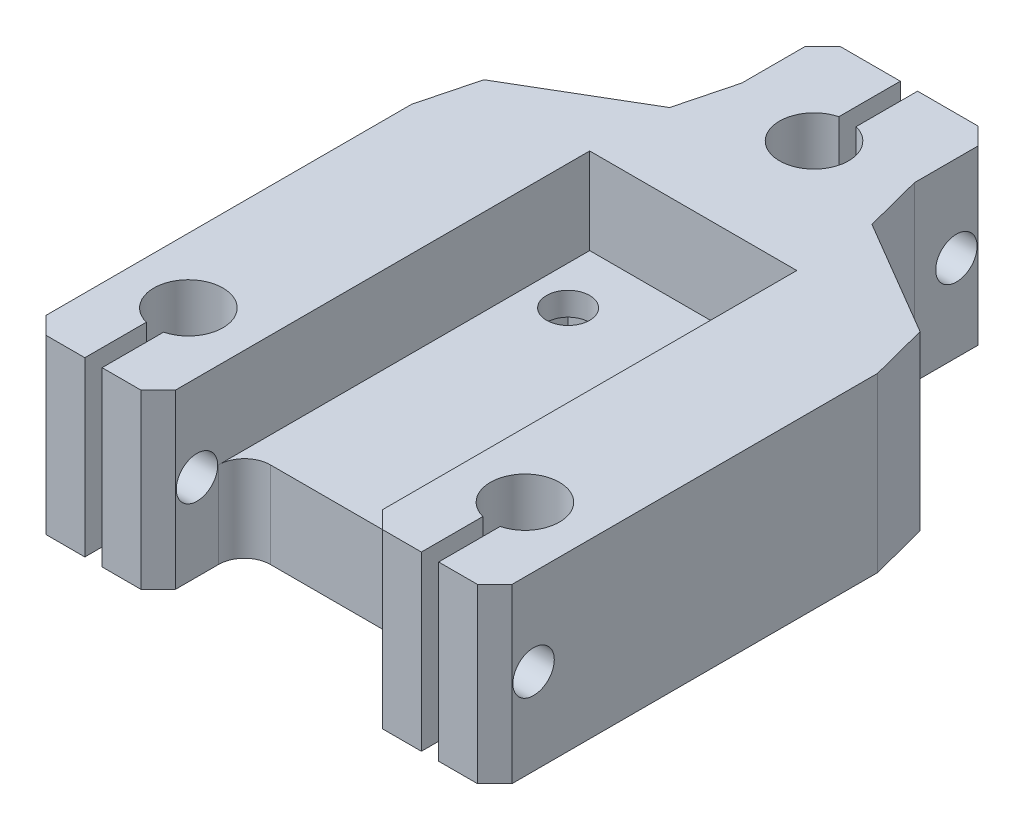
from build123d import *

# Parameters (mm, degrees)
SKETCH1_W             = 24
SKETCH1_H             = 40
SKETCH1_R             = 2.5
BOSS_EXTRUDE1_DEPTH   = 10
SKETCH2_R             = 4
BOSS_EXTRUDE2_DEPTH   = 20
SKETCH4_W             = 2
SKETCH4_H             = 15
CUT_EXTRUDE1_DEPTH    = 20
SKETCH5_R             = 2.4
CUT_EXTRUDE2_DEPTH    = 56
CHAMFER2_SIZE         = 2
CHAMFER3_SIZE2        = 2
CHAMFER3_SIZE         = 5.63516655
CHAMFER3_EDGE_2_SIZE2 = 5.63516655
CHAMFER3_EDGE_2_SIZE  = 2
CHAMFER3_EDGE_3_SIZE2 = 2
CHAMFER3_EDGE_3_SIZE  = 5.63516655
CHAMFER3_EDGE_4_SIZE2 = 5.63516655
CHAMFER3_EDGE_4_SIZE  = 2
FILLET2_R             = 3
SKETCH6_W             = 28
SKETCH6_H             = 13
CUT_EXTRUDE3_DEPTH    = 7.3


with BuildPart() as part:
    # Sketch1 → Boss-Extrude1 (new body)
    with BuildSketch(Plane(origin=(0, 0, 0), x_dir=(1, 0, 0), z_dir=(0, 1, 0))):
        Rectangle(SKETCH1_W, SKETCH1_H)
        with Locations((7.5, 13)):
            Circle(SKETCH1_R, mode=Mode.SUBTRACT)
        with Locations((-7.5, 13)):
            Circle(SKETCH1_R, mode=Mode.SUBTRACT)
    extrude(amount=BOSS_EXTRUDE1_DEPTH)

    # Sketch2 → Boss-Extrude2 (add)
    with BuildSketch(Plane.XZ):
        Polygon((-12, -20), (-12, 30), (-27, 30), (-27, -20), (-10, -30), (-10, -45), (10, -45), (10, -30), (27, -20), (27, 30), (12, 30), (12, -20), align=None)
        with Locations((0, -34)):
            Circle(SKETCH2_R, mode=Mode.SUBTRACT)
        with Locations((-19.5, 19)):
            Circle(SKETCH2_R, mode=Mode.SUBTRACT)
        with Locations((19.5, 19)):
            Circle(SKETCH2_R, mode=Mode.SUBTRACT)
    extrude(amount=-BOSS_EXTRUDE2_DEPTH)

    # Sketch4 → Cut-Extrude1 (cut)
    with BuildSketch(Plane(origin=(0, 20, 0), x_dir=(1, 0, 0), z_dir=(0, 1, 0))):
        with Locations((19.5, -30)):
            Rectangle(SKETCH4_W, SKETCH4_H)
        with Locations((-19.5, -30)):
            Rectangle(SKETCH4_W, SKETCH4_H)
        with Locations((0, 45)):
            Rectangle(SKETCH4_W, SKETCH4_H)
    extrude(amount=-CUT_EXTRUDE1_DEPTH, mode=Mode.SUBTRACT)

    # Sketch5 → Cut-Extrude2 (cut)
    with BuildSketch(Plane(origin=(27, 0, 0), x_dir=(0, 0, -1), z_dir=(1, 0, 0))):
        with Locations((-25.5, 10)):
            Circle(SKETCH5_R)
        with Locations((40.5, 10)):
            Circle(SKETCH5_R)
    extrude(amount=-CUT_EXTRUDE2_DEPTH, mode=Mode.SUBTRACT)

    # Chamfer2
    chamfer2_edges = [part.edges().sort_by_distance(p)[0] for p in [
        (12, 10, 30),
        (27, 10, 30),
        (10, 10, -45),
        (-10, 10, -45),
        (-27, 10, 30),
        (-12, 10, 30),
    ]]
    chamfer(chamfer2_edges, length=CHAMFER2_SIZE)

    # Chamfer3
    chamfer3_edges = [part.edges().sort_by_distance(p)[0] for p in [
        (27, 10, -20),
    ]]
    chamfer(chamfer3_edges, length=CHAMFER3_SIZE, length2=CHAMFER3_SIZE2)

    # Chamfer3 edge 2
    chamfer3_edge_2_edges = [part.edges().sort_by_distance(p)[0] for p in [
        (10, 10, -30),
    ]]
    chamfer(chamfer3_edge_2_edges, length=CHAMFER3_EDGE_2_SIZE, length2=CHAMFER3_EDGE_2_SIZE2)

    # Chamfer3 edge 3
    chamfer3_edge_3_edges = [part.edges().sort_by_distance(p)[0] for p in [
        (-10, 10, -30),
    ]]
    chamfer(chamfer3_edge_3_edges, length=CHAMFER3_EDGE_3_SIZE, length2=CHAMFER3_EDGE_3_SIZE2)

    # Chamfer3 edge 4
    chamfer3_edge_4_edges = [part.edges().sort_by_distance(p)[0] for p in [
        (-27, 10, -20),
    ]]
    chamfer(chamfer3_edge_4_edges, length=CHAMFER3_EDGE_4_SIZE, length2=CHAMFER3_EDGE_4_SIZE2)

    # Fillet2
    fillet2_edges = [part.edges().sort_by_distance(p)[0] for p in [
        (12, 5, 20),
        (-12, 5, 20),
    ]]
    fillet(fillet2_edges, radius=FILLET2_R)

    # Sketch6 → Cut-Extrude3 (cut)
    with BuildSketch(Plane.XZ):
        with Locations((0, -13)):
            Rectangle(SKETCH6_W, SKETCH6_H)
    extrude(amount=-CUT_EXTRUDE3_DEPTH, mode=Mode.SUBTRACT)


solid = part.part
